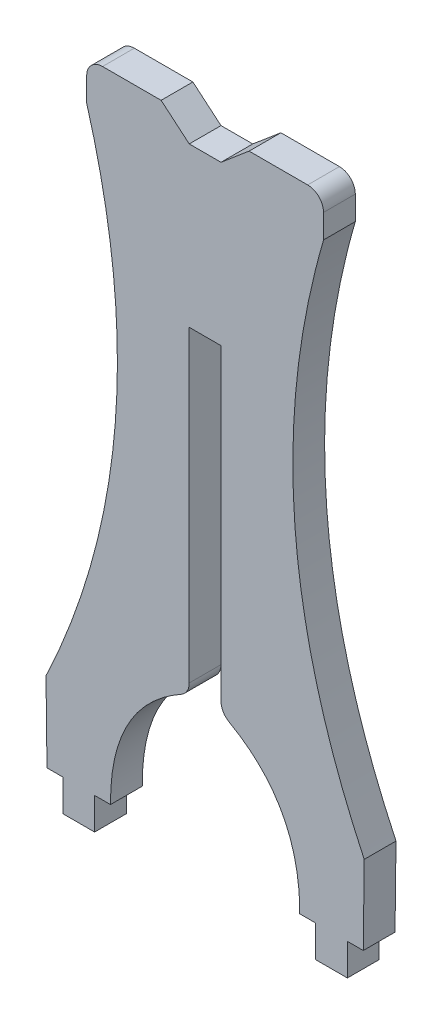
from build123d import *

# Parameters (mm, degrees)
BOSS_EXTRUDE2_DEPTH = 5.08
FILLET3_R           = 2.54
FILLET4_R           = 2.54


with BuildPart() as part:
    # Sketch3 → Boss-Extrude2 (new body)
    with BuildSketch(Plane.XY):
        with BuildLine():
            Line((0.14834484, -16.543006694), (-0.005888561, -3.843943262))
            add(Edge.make_bspline(
                [(6.500180425, 78.706993306), (18.901808207, 35.989935529), (-0.005888561, -3.843943262)],
                knots=[0, 0, 0, 1, 1, 1], degree=2))
            Line((6.500180425, 78.706993306), (6.500180425, 85.056993306))
            Line((6.500180425, 85.056993306), (18.406430425, 85.056993306))
            Line((18.406430425, 85.056993306), (22.903074533, 81.262968128))
            Line((22.903074533, 81.262968128), (27.983074533, 81.262968128))
            Line((27.983074533, 81.262968128), (32.479718641, 85.056993306))
            Line((32.479718641, 85.056993306), (44.385968641, 85.056993306))
            Line((44.385968641, 85.056993306), (44.385968641, 78.706993306))
            add(Edge.make_bspline(
                [(44.385968641, 78.706993306), (31.984340858, 35.989935529), (50.892037627, -3.843943262)],
                knots=[0, 0, 0, 1, 1, 1], degree=2))
            Line((50.892037627, -3.843943262), (50.737804225, -16.543006694))
            Line((50.737804225, -16.543006694), (48.197804225, -16.543006694))
            Line((48.197804225, -16.543006694), (48.197804225, -21.623006694))
            Line((48.197804225, -21.623006694), (43.117804225, -21.623006694))
            Line((43.117804225, -21.623006694), (43.117804225, -16.543006694))
            Line((43.117804225, -16.543006694), (40.577804225, -16.543006694))
            add(Edge.make_bspline(
                [(27.983074533, 5.062968128), (40.683819064, -1.22119794), (40.577804225, -16.543006694)],
                knots=[0, 0, 0, 1, 1, 1], degree=2))
            Line((27.983074533, 5.062968128), (27.983074533, 55.862968128))
            Line((27.983074533, 55.862968128), (22.903074533, 55.862968128))
            Line((22.903074533, 55.862968128), (22.903074533, 5.062968128))
            add(Edge.make_bspline(
                [(22.903074533, 5.062968128), (10.202330001, -1.22119794), (10.30834484, -16.543006694)],
                knots=[0, 0, 0, 1, 1, 1], degree=2))
            Line((10.30834484, -16.543006694), (7.76834484, -16.543006694))
            Line((7.76834484, -16.543006694), (7.76834484, -21.623006694))
            Line((7.76834484, -21.623006694), (2.68834484, -21.623006694))
            Line((2.68834484, -21.623006694), (2.68834484, -16.543006694))
            Line((2.68834484, -16.543006694), (0.14834484, -16.543006694))
        make_face()
    extrude(amount=BOSS_EXTRUDE2_DEPTH)

    # Fillet3
    fillet3_edges = [part.edges().sort_by_distance(p)[0] for p in [
        (6.500180425, 85.056993306, 2.54),
        (44.385968641, 85.056993306, 2.54),
    ]]
    fillet(fillet3_edges, radius=FILLET3_R)

    # Fillet4
    fillet4_edges = [part.edges().sort_by_distance(p)[0] for p in [
        (27.983074533, 5.062968128, 2.54),
        (22.903074533, 5.062968128, 2.54),
    ]]
    fillet(fillet4_edges, radius=FILLET4_R)


solid = part.part
